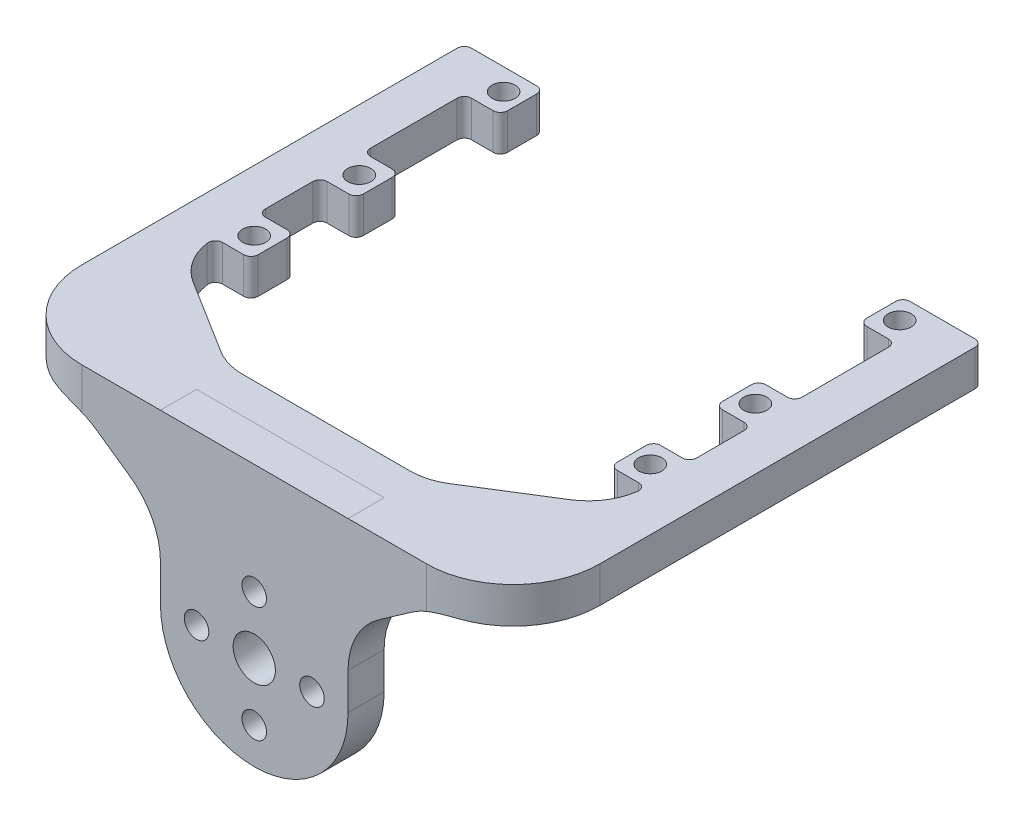
from build123d import *

# Parameters (mm, degrees)
EXTRUDE_1_DEPTH      = 3
SKETCH_7_R           = 2.25
CUT_EXTRUDE_2_DEPTH  = 4.0000001
SKETCH_8_R           = 8
CUT_EXTRUDE_3_DEPTH  = 4.0000001
CUT_EXTRUDE_4_DEPTH  = 3
CUT_EXTRUDE_5_DEPTH  = 3
CUT_EXTRUDE_8_DEPTH  = 3
SKETCH_12_R          = 1.7
CUT_EXTRUDE_9_DEPTH  = 3
SKETCH_13_R          = 1.7
CUT_EXTRUDE_11_DEPTH = 3
CUT_EXTRUDE_12_DEPTH = 4.0000001
FILLET_1_R           = 2
FILLET_2_R           = 2
CUT_EXTRUDE_13_DEPTH = 4.0000001
CUT_EXTRUDE_14_DEPTH = 4.0000001
CUT_EXTRUDE_15_DEPTH = 4.0000001
CUT_EXTRUDE_16_DEPTH = 4.0000001
SKETCH_19_W          = 174.604309186
SKETCH_19_H          = 153.794857067
CUT_EXTRUDE_17_DEPTH = 10
SKETCH_20_R          = 1.7
SKETCH_20_R_2        = 2.929115441
EXTRUDE_2_DEPTH      = 5
SKETCH_21_W          = 71.778327268
SKETCH_21_H          = 4.999657954
EXTRUDE_3_DEPTH      = 5
EXTRUDE_4_DEPTH      = 5
FILLET_3_R           = 10
SKETCH_23_W          = 71.778327268
SKETCH_23_H          = 4.999657954
EXTRUDE_5_DEPTH      = 5
FILLET_4_R           = 1
SKETCH_24_W          = 6
SKETCH_24_H          = 4.999657954
EXTRUDE_7_DEPTH      = 55
EXTRUDE_8_DEPTH      = 4.999658
FILLET_5_R           = 8
FILLET_6_R           = 12
SKETCH_27_W          = 5
SKETCH_27_H          = 6
EXTRUDE_9_DEPTH      = 4.999658
FILLET_7_R           = 1
FILLET_8_R           = 1
FILLET_9_R           = 1
SKETCH_28_R          = 1.6
CUT_EXTRUDE_19_DEPTH = 50
EXTRUDE_10_DEPTH     = 6
SKETCH_33_R          = 1.6
CUT_EXTRUDE_21_DEPTH = 10.999657954
SKETCH_34_W          = 162.843072653
SKETCH_34_H          = 93.113374014
CUT_EXTRUDE_22_DEPTH = 10
SKETCH_35_W          = 6
SKETCH_35_H          = 6
SKETCH_35_R          = 1.6
EXTRUDE_11_DEPTH     = 1
CUT_EXTRUDE_24_DEPTH = 10


with BuildPart() as part:
    # 草图1 → 凸台-拉伸1 (new body)
    with BuildSketch(Plane.XY):
        with BuildLine():
            Line((60, 106.603296002), (35.889163634, 121.664519159))
            Line((35.889163634, 121.664519159), (-35.889163634, 121.664519159))
            Line((-35.889163634, 121.664519159), (-60, 106.603296002))
            Line((-60, 106.603296002), (-60, 94.801892265))
            Line((-60, 94.801892265), (-45, 94.801892265))
            ThreePointArc((-45, 94.801892265), (-43.762563133, 94.289329132), (-43.25, 93.051892265))
            Line((-43.25, 93.051892265), (-37.75, 93.051892265))
            ThreePointArc((-37.75, 93.051892265), (-37.237436867, 94.289329132), (-36, 94.801892265))
            Line((-36, 94.801892265), (-21, 94.801892265))
            ThreePointArc((-21, 94.801892265), (-19.762563133, 94.289329132), (-19.25, 93.051892265))
            Line((-19.25, 93.051892265), (19.25, 93.051892265))
            ThreePointArc((19.25, 93.051892265), (19.762563133, 94.289329132), (21, 94.801892265))
            Line((21, 94.801892265), (36, 94.801892265))
            ThreePointArc((36, 94.801892265), (37.237436867, 94.289329132), (37.75, 93.051892265))
            Line((37.75, 93.051892265), (43.25, 93.051892265))
            ThreePointArc((43.25, 93.051892265), (43.762563133, 94.289329132), (45, 94.801892265))
            Line((45, 94.801892265), (60, 94.801892265))
            Line((60, 94.801892265), (60, 106.603296002))
        make_face()
        with BuildLine():
            Line((66.901694095, 102.292041372), (60, 106.603296002))
            Line((60, 106.603296002), (60, 94.801892265))
            ThreePointArc((60, 94.801892265), (61.237436867, 94.289329132), (61.75, 93.051892265))
            Line((61.75, 93.051892265), (66.901694095, 93.051892265))
            Line((66.901694095, 93.051892265), (66.901694095, 102.292041372))
        make_face()
        with BuildLine():
            Line((-60, 94.801892265), (-60, 106.603296002))
            Line((-60, 106.603296002), (-66.901694095, 102.292041372))
            Line((-66.901694095, 102.292041372), (-66.901694095, 93.051892265))
            Line((-66.901694095, 93.051892265), (-61.75, 93.051892265))
            ThreePointArc((-61.75, 93.051892265), (-61.237436867, 94.289329132), (-60, 94.801892265))
        make_face()
        with BuildLine():
            Line((66.901694095, 63.051892265), (66.901694095, 93.051892265))
            Line((66.901694095, 93.051892265), (61.75, 93.051892265))
            ThreePointArc((61.75, 93.051892265), (61.237436867, 91.814455398), (60, 91.301892265))
            Line((60, 91.301892265), (60, 64.801892265))
            ThreePointArc((60, 64.801892265), (61.237436867, 64.289329132), (61.75, 63.051892265))
            Line((61.75, 63.051892265), (66.901694095, 63.051892265))
        make_face()
        with BuildLine():
            Line((-61.75, 93.051892265), (-66.901694095, 93.051892265))
            Line((-66.901694095, 93.051892265), (-66.901694095, 63.051892265))
            Line((-66.901694095, 63.051892265), (-61.75, 63.051892265))
            ThreePointArc((-61.75, 63.051892265), (-61.237436867, 64.289329132), (-60, 64.801892265))
            Line((-60, 64.801892265), (-60, 91.301892265))
            ThreePointArc((-60, 91.301892265), (-61.237436867, 91.814455398), (-61.75, 93.051892265))
        make_face()
        with BuildLine():
            Line((66.901694095, 52.870133869), (66.901694095, 63.051892265))
            Line((66.901694095, 63.051892265), (61.75, 63.051892265))
            ThreePointArc((61.75, 63.051892265), (61.237436867, 61.814455398), (60, 61.301892265))
            Line((60, 61.301892265), (60, 31.261343001))
            Line((60, 31.261343001), (75, 31.261343001))
            Line((75, 31.261343001), (75, 40.933889795))
            ThreePointArc((75, 40.933889795), (69.117351927, 45.658052319), (66.901694095, 52.870133869))
        make_face()
        with BuildLine():
            Line((60, 64.801892265), (60, 91.301892265))
            Line((60, 91.301892265), (45, 91.301892265))
            ThreePointArc((45, 91.301892265), (43.762563133, 91.814455398), (43.25, 93.051892265))
            Line((43.25, 93.051892265), (37.75, 93.051892265))
            ThreePointArc((37.75, 93.051892265), (37.237436867, 91.814455398), (36, 91.301892265))
            Line((36, 91.301892265), (21, 91.301892265))
            ThreePointArc((21, 91.301892265), (19.762563133, 91.814455398), (19.25, 93.051892265))
            Line((19.25, 93.051892265), (-19.25, 93.051892265))
            ThreePointArc((-19.25, 93.051892265), (-19.762563133, 91.814455398), (-21, 91.301892265))
            Line((-21, 91.301892265), (-36, 91.301892265))
            ThreePointArc((-36, 91.301892265), (-37.237436867, 91.814455398), (-37.75, 93.051892265))
            Line((-37.75, 93.051892265), (-43.25, 93.051892265))
            ThreePointArc((-43.25, 93.051892265), (-43.762563133, 91.814455398), (-45, 91.301892265))
            Line((-45, 91.301892265), (-60, 91.301892265))
            Line((-60, 91.301892265), (-60, 64.801892265))
            Line((-60, 64.801892265), (-45, 64.801892265))
            ThreePointArc((-45, 64.801892265), (-43.762563133, 64.289329132), (-43.25, 63.051892265))
            Line((-43.25, 63.051892265), (-37.75, 63.051892265))
            ThreePointArc((-37.75, 63.051892265), (-37.237436867, 64.289329132), (-36, 64.801892265))
            Line((-36, 64.801892265), (-21, 64.801892265))
            ThreePointArc((-21, 64.801892265), (-19.762563133, 64.289329132), (-19.25, 63.051892265))
            Line((-19.25, 63.051892265), (19.25, 63.051892265))
            ThreePointArc((19.25, 63.051892265), (19.762563133, 64.289329132), (21, 64.801892265))
            Line((21, 64.801892265), (36, 64.801892265))
            ThreePointArc((36, 64.801892265), (37.237436867, 64.289329132), (37.75, 63.051892265))
            Line((37.75, 63.051892265), (43.25, 63.051892265))
            ThreePointArc((43.25, 63.051892265), (43.762563133, 64.289329132), (45, 64.801892265))
            Line((45, 64.801892265), (60, 64.801892265))
        make_face()
        with BuildLine():
            Line((-61.75, 63.051892265), (-66.901694095, 63.051892265))
            Line((-66.901694095, 63.051892265), (-66.901694095, 52.870133869))
            ThreePointArc((-66.901694095, 52.870133869), (-69.117351927, 45.658052319), (-75, 40.933889795))
            Line((-75, 40.933889795), (-75, 31.261343001))
            Line((-75, 31.261343001), (-60, 31.261343001))
            Line((-60, 31.261343001), (-60, 61.301892265))
            ThreePointArc((-60, 61.301892265), (-61.237436867, 61.814455398), (-61.75, 63.051892265))
        make_face()
        with BuildLine():
            Line((60, 31.261343001), (60, 61.301892265))
            Line((60, 61.301892265), (45, 61.301892265))
            ThreePointArc((45, 61.301892265), (43.762563133, 61.814455398), (43.25, 63.051892265))
            Line((43.25, 63.051892265), (37.75, 63.051892265))
            ThreePointArc((37.75, 63.051892265), (37.237436867, 61.814455398), (36, 61.301892265))
            Line((36, 61.301892265), (21, 61.301892265))
            ThreePointArc((21, 61.301892265), (19.762563133, 61.814455398), (19.25, 63.051892265))
            Line((19.25, 63.051892265), (-19.25, 63.051892265))
            ThreePointArc((-19.25, 63.051892265), (-19.762563133, 61.814455398), (-21, 61.301892265))
            Line((-21, 61.301892265), (-36, 61.301892265))
            ThreePointArc((-36, 61.301892265), (-37.237436867, 61.814455398), (-37.75, 63.051892265))
            Line((-37.75, 63.051892265), (-43.25, 63.051892265))
            ThreePointArc((-43.25, 63.051892265), (-43.762563133, 61.814455398), (-45, 61.301892265))
            Line((-45, 61.301892265), (-60, 61.301892265))
            Line((-60, 61.301892265), (-60, 31.261343001))
            Line((-60, 31.261343001), (60, 31.261343001))
        make_face()
        with BuildLine():
            Line((60, -58.312864289), (60, 23.940028391))
            Line((60, 23.940028391), (-60, 23.940028391))
            Line((-60, 23.940028391), (-60, -58.312864289))
            Line((-60, -58.312864289), (-45, -58.312864289))
            ThreePointArc((-45, -58.312864289), (-43.25, -60.062864289), (-45, -61.812864289))
            Line((-45, -61.812864289), (-60, -61.812864289))
            Line((-60, -61.812864289), (-60, -88.312864289))
            Line((-60, -88.312864289), (-45, -88.312864289))
            ThreePointArc((-45, -88.312864289), (-43.25, -90.062864289), (-45, -91.812864289))
            Line((-45, -91.812864289), (-60, -91.812864289))
            Line((-60, -91.812864289), (-60, -111.849967256))
            Line((-60, -111.849967256), (-38.845469114, -105.590576733))
            ThreePointArc((-38.845469114, -105.590576733), (-36.037784492, -104.975210108), (-33.17088573, -104.768665882))
            Line((-33.17088573, -104.768665882), (33.17088573, -104.768665882))
            ThreePointArc((33.17088573, -104.768665882), (36.037784492, -104.975210108), (38.845469114, -105.590576733))
            Line((38.845469114, -105.590576733), (60, -111.849967256))
            Line((60, -111.849967256), (60, -91.812864289))
            Line((60, -91.812864289), (45, -91.812864289))
            ThreePointArc((45, -91.812864289), (43.762563133, -91.300301156), (43.25, -90.062864289))
            ThreePointArc((43.25, -90.062864289), (43.762563133, -88.825427422), (45, -88.312864289))
            Line((45, -88.312864289), (60, -88.312864289))
            Line((60, -88.312864289), (60, -61.812864289))
            Line((60, -61.812864289), (45, -61.812864289))
            ThreePointArc((45, -61.812864289), (43.762563133, -61.300301156), (43.25, -60.062864289))
            ThreePointArc((43.25, -60.062864289), (43.762563133, -58.825427422), (45, -58.312864289))
            Line((45, -58.312864289), (60, -58.312864289))
        make_face()
        with BuildLine():
            ThreePointArc((-21, -88.312864289), (-19.762563133, -88.825427422), (-19.25, -90.062864289))
            ThreePointArc((-19.25, -90.062864289), (-19.762563133, -91.300301156), (-21, -91.812864289))
            Line((-21, -91.812864289), (-36, -91.812864289))
            ThreePointArc((-36, -91.812864289), (-37.75, -90.062864289), (-36, -88.312864289))
            Line((-36, -88.312864289), (-21, -88.312864289))
        make_face(mode=Mode.SUBTRACT)
        with BuildLine():
            ThreePointArc((-21, -58.312864289), (-19.762563133, -58.825427422), (-19.25, -60.062864289))
            ThreePointArc((-19.25, -60.062864289), (-19.762563133, -61.300301156), (-21, -61.812864289))
            Line((-21, -61.812864289), (-36, -61.812864289))
            ThreePointArc((-36, -61.812864289), (-37.75, -60.062864289), (-36, -58.312864289))
            Line((-36, -58.312864289), (-21, -58.312864289))
        make_face(mode=Mode.SUBTRACT)
        with BuildLine():
            ThreePointArc((36, -88.312864289), (37.237436867, -88.825427422), (37.75, -90.062864289))
            ThreePointArc((37.75, -90.062864289), (37.237436867, -91.300301156), (36, -91.812864289))
            Line((36, -91.812864289), (21, -91.812864289))
            ThreePointArc((21, -91.812864289), (19.762563133, -91.300301156), (19.25, -90.062864289))
            ThreePointArc((19.25, -90.062864289), (19.762563133, -88.825427422), (21, -88.312864289))
            Line((21, -88.312864289), (36, -88.312864289))
        make_face(mode=Mode.SUBTRACT)
        with BuildLine():
            ThreePointArc((36, -58.312864289), (37.237436867, -58.825427422), (37.75, -60.062864289))
            ThreePointArc((37.75, -60.062864289), (37.237436867, -61.300301156), (36, -61.812864289))
            Line((36, -61.812864289), (21, -61.812864289))
            ThreePointArc((21, -61.812864289), (19.762563133, -61.300301156), (19.25, -60.062864289))
            ThreePointArc((19.25, -60.062864289), (19.762563133, -58.825427422), (21, -58.312864289))
            Line((21, -58.312864289), (36, -58.312864289))
        make_face(mode=Mode.SUBTRACT)
        with BuildLine():
            Line((75, 23.940028391), (60, 23.940028391))
            Line((60, 23.940028391), (60, -58.312864289))
            ThreePointArc((60, -58.312864289), (61.237436867, -58.825427422), (61.75, -60.062864289))
            Line((61.75, -60.062864289), (67.402721334, -60.062864289))
            add(Edge.make_bspline(
                [(75, 10.562559835), (72.695878257, 1.907314233), (70.339582535, -13.372796253), (67.818206704, -36.939032951), (67.208860388, -51.77269444), (67.402721334, -60.062864289)],
                knots=[0, 0, 0, 0, 0.235246678, 0.40629419, 0.624108181, 0.624108181, 0.624108181, 0.624108181], degree=3))
            Line((75, 10.562559835), (75, 23.940028391))
        make_face()
        with BuildLine():
            Line((-60, -58.312864289), (-60, 23.940028391))
            Line((-60, 23.940028391), (-75, 23.940028391))
            Line((-75, 23.940028391), (-75, 10.562559835))
            add(Edge.make_bspline(
                [(-75, 10.562559835), (-72.695878257, 1.907314233), (-70.339582535, -13.372796253), (-67.818206704, -36.939032951), (-67.208860388, -51.77269444), (-67.402721334, -60.062864289)],
                knots=[0, 0, 0, 0, 0.235246678, 0.40629419, 0.624108181, 0.624108181, 0.624108181, 0.624108181], degree=3))
            add(Edge.make_bspline(
                [(-67.402721334, -60.062864289), (-67.560325872, -66.802583754), (-68.323504015, -76.843670093), (-70.154131955, -86.778530076), (-70.533712858, -90.062864289)],
                knots=[0.624108181, 0.624108181, 0.624108181, 0.624108181, 0.801186001, 0.888408652, 0.888408652, 0.888408652, 0.888408652], degree=3))
            add(Edge.make_bspline(
                [(-70.533712858, -90.062864289), (-71.019342956, -94.264792095), (-71.137422935, -98.476048206), (-70.1742624, -102.732794059)],
                knots=[0.888408652, 0.888408652, 0.888408652, 0.888408652, 1, 1, 1, 1], degree=3))
            Line((-70.1742624, -102.732794059), (-66.460817635, -113.761651372))
            Line((-66.460817635, -113.761651372), (-60, -111.849967256))
            Line((-60, -111.849967256), (-60, -91.812864289))
            ThreePointArc((-60, -91.812864289), (-61.75, -90.062864289), (-60, -88.312864289))
            Line((-60, -88.312864289), (-60, -61.812864289))
            ThreePointArc((-60, -61.812864289), (-61.75, -60.062864289), (-60, -58.312864289))
        make_face()
        with BuildLine():
            Line((67.402721334, -60.062864289), (61.75, -60.062864289))
            ThreePointArc((61.75, -60.062864289), (61.237436867, -61.300301156), (60, -61.812864289))
            Line((60, -61.812864289), (60, -88.312864289))
            ThreePointArc((60, -88.312864289), (61.237436867, -88.825427422), (61.75, -90.062864289))
            Line((61.75, -90.062864289), (70.533712858, -90.062864289))
            add(Edge.make_bspline(
                [(67.402721334, -60.062864289), (67.560325872, -66.802583754), (68.323504015, -76.843670093), (70.154131955, -86.778530076), (70.533712858, -90.062864289)],
                knots=[0.624108181, 0.624108181, 0.624108181, 0.624108181, 0.801186001, 0.888408652, 0.888408652, 0.888408652, 0.888408652], degree=3))
        make_face()
        with BuildLine():
            add(Edge.make_bspline(
                [(70.533712858, -90.062864289), (71.019342956, -94.264792095), (71.137422935, -98.476048206), (70.1742624, -102.732794059)],
                knots=[0.888408652, 0.888408652, 0.888408652, 0.888408652, 1, 1, 1, 1], degree=3))
            Line((70.533712858, -90.062864289), (61.75, -90.062864289))
            ThreePointArc((61.75, -90.062864289), (61.237436867, -91.300301156), (60, -91.812864289))
            Line((60, -91.812864289), (60, -111.849967256))
            Line((60, -111.849967256), (66.460817635, -113.761651372))
            Line((66.460817635, -113.761651372), (70.1742624, -102.732794059))
        make_face()
    extrude(amount=EXTRUDE_1_DEPTH)

    # 草图7 → 切除-拉伸2 (cut, through all)
    with BuildSketch(Plane(origin=(0, 0, 0), x_dir=(-1, 0, 0), z_dir=(0, 0, -1))):
        with Locations((-21, 41.261343001)):
            Circle(SKETCH_7_R)
        with Locations((21, 41.261343001)):
            Circle(SKETCH_7_R)
        with Locations((-21, 13.940028391)):
            Circle(SKETCH_7_R)
        with Locations((21, 13.940028391)):
            Circle(SKETCH_7_R)
    extrude(amount=-CUT_EXTRUDE_2_DEPTH, mode=Mode.SUBTRACT)

    # 草图8 → 切除-拉伸3 (cut, through all)
    with BuildSketch(Plane.XY.offset(3)):
        with BuildLine():
            Line((-12.621438714, -0.378557945), (-33.409010345, 20.409013685))
            ThreePointArc((-33.409010345, 20.409013685), (-36.590999434, 20.409013643), (-36.590999309, 17.227024553))
            Line((-36.590999309, 17.227024553), (-15.803426586, -3.560545984))
            ThreePointArc((-15.803426586, -3.560545984), (-12.621438673, -3.560545859), (-12.621438714, -0.378557945))
        make_face()
        with BuildLine():
            Line((33.410462056, 20.410458798), (12.572988319, -0.427010824))
            ThreePointArc((12.572988319, -0.427010824), (12.644570441, -3.584764993), (15.803045702, -3.56090242))
            Line((15.803045702, -3.56090242), (34.999999982, 15.636052774))
            Line((34.999999982, 15.636052774), (36.588086952, 17.224139819))
            ThreePointArc((36.588086952, 17.224139819), (36.592433993, 20.406111757), (33.410462056, 20.410458798))
        make_face()
        with BuildLine():
            Line((-15.803784812, -28.80377835), (-36.591002186, -49.590991619))
            ThreePointArc((-36.591002186, -49.590991619), (-36.591002403, -52.772972232), (-33.40902179, -52.772972254))
            Line((-33.40902179, -52.772972254), (-12.573723916, -31.937673388))
            ThreePointArc((-12.573723916, -31.937673388), (-12.64530628, -28.779915954), (-15.803784812, -28.80377835))
        make_face()
        with BuildLine():
            Line((36.590992666, -49.590989326), (15.803414627, -28.803411286))
            ThreePointArc((15.803414627, -28.803411286), (12.654338964, -28.769774302), (12.55344336, -31.917412949))
            Line((12.55344336, -31.917412949), (33.409007381, -52.772974779))
            ThreePointArc((33.409007381, -52.772974779), (36.590992708, -52.772974653), (36.590992666, -49.590989326))
        make_face()
        with Locations((-0.000368782, -16.182341354)):
            Circle(SKETCH_8_R)
    extrude(amount=-CUT_EXTRUDE_3_DEPTH, mode=Mode.SUBTRACT)

    # 草图9 → 切除-拉伸4 (cut)
    with BuildSketch(Plane.XY.offset(3)):
        with BuildLine():
            Line((55, -100.49704609), (20, -100.49704609))
            ThreePointArc((20, -100.49704609), (18.25, -98.74704609), (20, -96.99704609))
            Line((20, -96.99704609), (55, -96.99704609))
            ThreePointArc((55, -96.99704609), (56.75, -98.74704609), (55, -100.49704609))
        make_face()
        with BuildLine():
            Line((-55, -96.99704609), (-20, -96.99704609))
            ThreePointArc((-20, -96.99704609), (-18.25, -98.74704609), (-20, -100.49704609))
            Line((-20, -100.49704609), (-55, -100.49704609))
            ThreePointArc((-55, -100.49704609), (-56.75, -98.74704609), (-55, -96.99704609))
        make_face()
    extrude(amount=-CUT_EXTRUDE_4_DEPTH, mode=Mode.SUBTRACT)

    # 草图10 → 切除-拉伸5 (cut)
    with BuildSketch(Plane.XY.offset(3)):
        with BuildLine():
            Line((12.5, -80.062864289), (-12.5, -80.062864289))
            ThreePointArc((-12.5, -80.062864289), (-17.5, -75.062864289), (-12.5, -70.062864289))
            Line((-12.5, -70.062864289), (12.5, -70.062864289))
            ThreePointArc((12.5, -70.062864289), (17.5, -75.062864289), (12.5, -80.062864289))
        make_face()
    extrude(amount=-CUT_EXTRUDE_5_DEPTH, mode=Mode.SUBTRACT)

    # 草图11 → 切除-拉伸8 (cut)
    with BuildSketch(Plane.XY.offset(3)):
        with BuildLine():
            Line((15, 73.051892265), (-15, 73.051892265))
            ThreePointArc((-15, 73.051892265), (-20, 78.051892265), (-15, 83.051892265))
            Line((-15, 83.051892265), (15, 83.051892265))
            ThreePointArc((15, 83.051892265), (20, 78.051892265), (15, 73.051892265))
        make_face()
    extrude(amount=-CUT_EXTRUDE_8_DEPTH, mode=Mode.SUBTRACT)

    # 草图12 → 切除-拉伸9 (cut)
    with BuildSketch(Plane.XY.offset(3)):
        with Locations((0, 114.371786435)):
            Circle(SKETCH_12_R)
        with Locations((0, 98.371786435)):
            Circle(SKETCH_12_R)
        with Locations((8, 106.371786435)):
            Circle(SKETCH_12_R)
        with Locations((-8, 106.371786435)):
            Circle(SKETCH_12_R)
    extrude(amount=-CUT_EXTRUDE_9_DEPTH, mode=Mode.SUBTRACT)

    # 草图13 → 切除-拉伸11 (cut)
    with BuildSketch(Plane.XY.offset(3)):
        with Locations((0, -84.415765086)):
            Circle(SKETCH_13_R)
        with Locations((8, -92.415765086)):
            Circle(SKETCH_13_R)
        with Locations((0, -100.415765086)):
            Circle(SKETCH_13_R)
        with Locations((-8, -92.415765086)):
            Circle(SKETCH_13_R)
    extrude(amount=-CUT_EXTRUDE_11_DEPTH, mode=Mode.SUBTRACT)

    # 草图14 → 切除-拉伸12 (cut, through all)
    with BuildSketch(Plane.XY.offset(3)):
        with BuildLine():
            Line((-55.475501567, 8.919687236), (-55.475501567, -46.080312764))
            ThreePointArc((-55.475501567, -46.080312764), (-57.225501567, -47.830312764), (-58.975501567, -46.080312764))
            Line((-58.975501567, -46.080312764), (-58.975501567, 8.919687236))
            ThreePointArc((-58.975501567, 8.919687236), (-57.225501567, 10.669687236), (-55.475501567, 8.919687236))
        make_face()
        with BuildLine():
            Line((58.975501567, 8.919687236), (58.975501567, -46.080312764))
            ThreePointArc((58.975501567, -46.080312764), (57.225501567, -47.830312764), (55.475501567, -46.080312764))
            Line((55.475501567, -46.080312764), (55.475501567, 8.919687236))
            ThreePointArc((55.475501567, 8.919687236), (57.225501567, 10.669687236), (58.975501567, 8.919687236))
        make_face()
    extrude(amount=-CUT_EXTRUDE_12_DEPTH, mode=Mode.SUBTRACT)

    # 圆角1
    fillet_1_edges = [part.edges().sort_by_distance(p)[0] for p in [
        (75, 31.261343001, 1.5),
        (-75, 31.261343001, 1.5),
    ]]
    fillet(fillet_1_edges, radius=FILLET_1_R)

    # 圆角2
    fillet_2_edges = [part.edges().sort_by_distance(p)[0] for p in [
        (-75, 23.940028391, 1.5),
        (75, 23.940028391, 1.5),
    ]]
    fillet(fillet_2_edges, radius=FILLET_2_R)

    # 草图15 → 切除-拉伸13 (cut, through all)
    with BuildSketch(Plane(origin=(0, 0, 0), x_dir=(-1, 0, 0), z_dir=(0, 0, -1))):
        with BuildLine():
            Line((-61.184216401, 102.403501276), (-34.774762862, 118.900592756))
            ThreePointArc((-34.774762862, 118.900592756), (-32.70788159, 118.423097411), (-33.185376934, 116.356216138))
            Line((-33.185376934, 116.356216138), (-59.594830473, 99.859124658))
            ThreePointArc((-59.594830473, 99.859124658), (-61.661711746, 100.336620003), (-61.184216401, 102.403501276))
        make_face()
        with BuildLine():
            Line((59.594830473, 99.859124658), (33.185376934, 116.356216138))
            ThreePointArc((33.185376934, 116.356216138), (32.70788159, 118.423097411), (34.774762862, 118.900592756))
            Line((34.774762862, 118.900592756), (61.184216401, 102.403501276))
            ThreePointArc((61.184216401, 102.403501276), (61.661711746, 100.336620003), (59.594830473, 99.859124658))
        make_face()
    extrude(amount=-CUT_EXTRUDE_13_DEPTH, mode=Mode.SUBTRACT)

    # 草图16 → 切除-拉伸14 (cut, through all)
    with BuildSketch(Plane(origin=(0, 0, 0), x_dir=(-1, 0, 0), z_dir=(0, 0, -1))):
        with BuildLine():
            Line((-61.516979467, 42.761343001), (-32.056291893, 42.761343001))
            ThreePointArc((-32.056291893, 42.761343001), (-30.556291893, 41.261343001), (-32.056291893, 39.761343001))
            Line((-32.056291893, 39.761343001), (-61.516979467, 39.761343001))
            ThreePointArc((-61.516979467, 39.761343001), (-63.016979467, 41.261343001), (-61.516979467, 42.761343001))
        make_face()
        with BuildLine():
            Line((61.516979467, 39.761343001), (32.056291893, 39.761343001))
            ThreePointArc((32.056291893, 39.761343001), (30.556291893, 41.261343001), (32.056291893, 42.761343001))
            Line((32.056291893, 42.761343001), (61.516979467, 42.761343001))
            ThreePointArc((61.516979467, 42.761343001), (63.016979467, 41.261343001), (61.516979467, 39.761343001))
        make_face()
    extrude(amount=-CUT_EXTRUDE_14_DEPTH, mode=Mode.SUBTRACT)

    # 草图17 → 切除-拉伸15 (cut, through all)
    with BuildSketch(Plane(origin=(0, 0, 0), x_dir=(-1, 0, 0), z_dir=(0, 0, -1))):
        Polygon((-28.645414283, -8.118433382), (-34.644957411, -20.11751964), (-34.644957411, -29.946558382), (-37.580904049, -29.946558382), (-37.580904049, -20.11751964), (-43.580447177, -8.118433382), (-40.64450054, -8.118433382), (-36.176755657, -17.43687271), (-36.049105803, -17.43687271), (-31.58136092, -8.118433382), align=None)
    extrude(amount=-CUT_EXTRUDE_15_DEPTH, mode=Mode.SUBTRACT)

    # 草图18 → 切除-拉伸16 (cut, through all)
    with BuildSketch(Plane(origin=(0, 0, 0), x_dir=(-1, 0, 0), z_dir=(0, 0, -1))):
        Polygon((46.06697123, -29.087529791), (43.131024593, -29.087529791), (43.131024593, -18.875541487), (35.854982926, -18.875541487), (35.854982926, -29.087529791), (32.919036289, -29.087529791), (32.919036289, -7.259404791), (35.854982926, -7.259404791), (35.854982926, -16.450194265), (43.131024593, -16.450194265), (43.131024593, -7.259404791), (46.06697123, -7.259404791), align=None)
    extrude(amount=-CUT_EXTRUDE_16_DEPTH, mode=Mode.SUBTRACT)

    # 草图19 → 切除-拉伸17 (cut)
    with BuildSketch(Plane(origin=(0, 0, 0), x_dir=(-1, 0, 0), z_dir=(0, 0, -1))):
        with Locations((0, -49.372787161)):
            Rectangle(SKETCH_19_W, SKETCH_19_H)
    extrude(amount=-CUT_EXTRUDE_17_DEPTH, mode=Mode.SUBTRACT)

    # 草图34 → 切除-拉伸22 (cut)
    with BuildSketch(Plane(origin=(0, 0, 0), x_dir=(-1, 0, 0), z_dir=(0, 0, -1))):
        with Locations((1.208964771, 75.898201893)):
            Rectangle(SKETCH_34_W, SKETCH_34_H)
    extrude(amount=-CUT_EXTRUDE_22_DEPTH, mode=Mode.SUBTRACT)


with BuildPart() as body_2:
    # 草图20 → 凸台-拉伸2 (new body)
    with BuildSketch(Plane.XY.offset(13)):
        with BuildLine():
            Line((-13, 106.371786435), (-13, 129.664519159))
            Line((-13, 129.664519159), (13, 129.664519159))
            Line((13, 129.664519159), (13, 106.371786435))
            ThreePointArc((13, 106.371786435), (0, 93.371786435), (-13, 106.371786435))
        make_face()
        with Locations((0, 98.371786435)):
            Circle(SKETCH_20_R, mode=Mode.SUBTRACT)
        with Locations((-8, 106.371786435)):
            Circle(SKETCH_20_R, mode=Mode.SUBTRACT)
        with Locations((8, 106.371786435)):
            Circle(SKETCH_20_R, mode=Mode.SUBTRACT)
        with Locations((0, 114.371786435)):
            Circle(SKETCH_20_R, mode=Mode.SUBTRACT)
        with Locations((0, 106.371786435)):
            Circle(SKETCH_20_R_2, mode=Mode.SUBTRACT)
    extrude(amount=EXTRUDE_2_DEPTH)

    # 草图21 → 凸台-拉伸3 (add)
    with BuildSketch(Plane.XY.offset(18)):
        with Locations((0, 127.164522428)):
            Rectangle(SKETCH_21_W, SKETCH_21_H)
    extrude(amount=-EXTRUDE_3_DEPTH)

    # 草图22 → 凸台-拉伸4 (add)
    with BuildSketch(Plane.XY.offset(18)):
        Polygon((-24.444581817, 124.664693451), (-13, 116.664693451), (-13, 124.664693451), align=None)
        Polygon((24.444581817, 124.664693451), (13, 116.664693451), (13, 124.664693451), align=None)
    extrude(amount=-EXTRUDE_4_DEPTH)

    # 圆角3
    fillet_3_edges = [body_2.edges().sort_by_distance(p)[0] for p in [
        (-24.444581817, 124.664693451, 15.5),
        (-13, 116.664693451, 15.5),
        (24.444581817, 124.664693451, 15.5),
        (13, 116.664693451, 15.5),
    ]]
    fillet(fillet_3_edges, radius=FILLET_3_R)

    # 草图23 → 凸台-拉伸5 (add)
    with BuildSketch(Plane(origin=(0, 0, 13), x_dir=(-1, 0, 0), z_dir=(0, 0, -1))):
        with Locations((0, 127.164522428)):
            Rectangle(SKETCH_23_W, SKETCH_23_H)
    extrude(amount=EXTRUDE_5_DEPTH)

    # 圆角4
    fillet_4_edges = [body_2.edges().sort_by_distance(p)[0] for p in [
        (0, 124.664693451, 13),
    ]]
    fillet(fillet_4_edges, radius=FILLET_4_R)

    # 草图24 → 凸台-拉伸7 (add)
    with BuildSketch(Plane(origin=(0, 0, 8), x_dir=(-1, 0, 0), z_dir=(0, 0, -1))):
        with Locations((-32.889163634, 127.164522428)):
            Rectangle(SKETCH_24_W, SKETCH_24_H)
        with Locations((32.889163634, 127.164522428)):
            Rectangle(SKETCH_24_W, SKETCH_24_H)
    extrude(amount=EXTRUDE_7_DEPTH)

    # 草图25 → 凸台-拉伸8 (add)
    with BuildSketch(Plane(origin=(0, 129.664351405, 0), x_dir=(1, 0, 0), z_dir=(0, 1, 0))):
        Polygon((-29.889163634, 2), (-13.889163634, -8), (-29.889163634, -8), align=None)
        Polygon((29.889163634, -8), (13.889163634, -8), (29.889163634, 2), align=None)
    extrude(amount=-EXTRUDE_8_DEPTH)

    # 圆角5
    fillet_5_edges = [body_2.edges().sort_by_distance(p)[0] for p in [
        (-13.889163634, 127.164522405, 8),
        (-29.889163634, 127.164522405, -2),
        (13.889163634, 127.164522405, 8),
        (29.889163634, 127.164522405, -2),
    ]]
    fillet(fillet_5_edges, radius=FILLET_5_R)

    # 圆角6
    fillet_6_edges = [body_2.edges().sort_by_distance(p)[0] for p in [
        (35.889163634, 127.164522428, 18),
        (-35.889163634, 127.164522428, 18),
    ]]
    fillet(fillet_6_edges, radius=FILLET_6_R)

    # 草图27 → 凸台-拉伸9 (add)
    with BuildSketch(Plane(origin=(0, 129.664351405, 0), x_dir=(1, 0, 0), z_dir=(0, 1, 0))):
        with Locations((-27.389163634, 9.433981132)):
            Rectangle(SKETCH_27_W, SKETCH_27_H)
        with Locations((-27.389163634, 24)):
            Rectangle(SKETCH_27_W, SKETCH_27_H)
        with Locations((27.389163634, 24)):
            Rectangle(SKETCH_27_W, SKETCH_27_H)
        with Locations((27.389163634, 9.433981132)):
            Rectangle(SKETCH_27_W, SKETCH_27_H)
        with Locations((-27.389163634, 44)):
            Rectangle(SKETCH_27_W, SKETCH_27_H)
        with Locations((27.389163634, 44)):
            Rectangle(SKETCH_27_W, SKETCH_27_H)
    extrude(amount=-EXTRUDE_9_DEPTH)

    # 圆角7
    fillet_7_edges = [body_2.edges().sort_by_distance(p)[0] for p in [
        (29.889163634, 127.164522428, -6.433981132),
        (-29.889163634, 127.164522428, -6.433981132),
        (-29.889163634, 127.164522405, -12.433981132),
        (-29.889163634, 127.164522405, -41),
        (29.889163634, 127.164522405, -41),
        (-29.889163634, 127.164522405, -27),
        (-29.889163634, 127.164522405, -21),
        (29.889163634, 127.164522405, -21),
        (29.889163634, 127.164522405, -27),
        (29.889163634, 127.164522405, -12.433981132),
    ]]
    fillet(fillet_7_edges, radius=FILLET_7_R)

    # 圆角8
    fillet_8_edges = [body_2.edges().sort_by_distance(p)[0] for p in [
        (-24.889163634, 127.164522405, -6.433981132),
        (-24.889163634, 127.164522405, -12.433981132),
        (-24.889163634, 127.164522405, -41),
        (24.889163634, 127.164522405, -41),
        (-24.889163634, 127.164522405, -21),
        (-24.889163634, 127.164522405, -27),
        (24.889163634, 127.164522405, -21),
        (24.889163634, 127.164522405, -27),
        (24.889163634, 127.164522405, -12.433981132),
        (24.889163634, 127.164522405, -6.433981132),
    ]]
    fillet(fillet_8_edges, radius=FILLET_8_R)

    # 圆角9
    fillet_9_edges = [body_2.edges().sort_by_distance(p)[0] for p in [
        (35.889163634, 127.164522428, -47),
        (-35.889163634, 127.164522428, -47),
        (-24.889163634, 127.164522405, -47),
        (24.889163634, 127.164522405, -47),
    ]]
    fillet(fillet_9_edges, radius=FILLET_9_R)

    # 草图28 → 切除-拉伸19 (cut)
    with BuildSketch(Plane(origin=(0, 129.664351405, 0), x_dir=(1, 0, 0), z_dir=(0, 1, 0))):
        with Locations((-27.445843009, 44)):
            Circle(SKETCH_28_R)
        with Locations((-27.445843009, 24)):
            Circle(SKETCH_28_R)
        with Locations((-27.445843009, 9.433981132)):
            Circle(SKETCH_28_R)
        with Locations((27.445843009, 9.433981132)):
            Circle(SKETCH_28_R)
        with Locations((27.445843009, 24)):
            Circle(SKETCH_28_R)
        with Locations((27.445843009, 44)):
            Circle(SKETCH_28_R)
    extrude(amount=-CUT_EXTRUDE_19_DEPTH, mode=Mode.SUBTRACT)

    # 草图32 → 凸台-拉伸10 (add)
    with BuildSketch(Plane.XY.offset(-6.433981132)):
        Polygon((-35.889163634, 129.664351405), (-56.41665643, 116.841521654), (-58.663321092, 120.438106306), (-35.889163634, 134.664351405), (35.889163634, 134.664351405), (58.663321092, 120.438106306), (56.41665643, 116.841521654), (35.889163634, 129.664351405), align=None)
    extrude(amount=-EXTRUDE_10_DEPTH)

    # 草图33 → 切除-拉伸21 (cut, through all)
    with BuildSketch(Plane.XZ.offset(-124.664693451)):
        with Locations((-27.445843009, -9.433981132)):
            Circle(SKETCH_33_R)
        with Locations((27.445843009, -9.433981132)):
            Circle(SKETCH_33_R)
    extrude(amount=-CUT_EXTRUDE_21_DEPTH, mode=Mode.SUBTRACT)

    # 草图35 → 凸台-拉伸11 (add)
    with BuildSketch(Plane(origin=(0, 134.664351405, 0), x_dir=(1, 0, 0), z_dir=(0, 1, 0))):
        with Locations((-27.445843009, 9.433981132)):
            Rectangle(SKETCH_35_W, SKETCH_35_H)
        with Locations((-27.445843009, 9.433981132)):
            Circle(SKETCH_35_R, mode=Mode.SUBTRACT)
        with Locations((27.445843009, 9.433981132)):
            Rectangle(SKETCH_35_W, SKETCH_35_H)
        with Locations((27.445843009, 9.433981132)):
            Circle(SKETCH_35_R, mode=Mode.SUBTRACT)
    extrude(amount=EXTRUDE_11_DEPTH)

    # 草图36 → 切除-拉伸24 (cut)
    with BuildSketch(Plane(origin=(0, 0, -12.433981132), x_dir=(-1, 0, 0), z_dir=(0, 0, -1))):
        Polygon((25.889163634, 129.664351405), (28.889163634, 129.664351405), (35.889163634, 129.664351405), (56.41665643, 116.841521654), (58.663321092, 120.438106306), (35.889163634, 134.664351405), (30.445843009, 134.664351405), (30.445843009, 135.664351405), (24.445843009, 135.664351405), (24.445843009, 134.664351405), (-24.445843009, 134.664351405), (-24.445843009, 135.664351405), (-30.445843009, 135.664351405), (-30.445843009, 134.664351405), (-35.889163634, 134.664351405), (-58.663321092, 120.438106306), (-56.41665643, 116.841521654), (-35.889163634, 129.664351405), (-28.889163634, 129.664351405), (-25.889163634, 129.664351405), align=None)
    extrude(amount=-CUT_EXTRUDE_24_DEPTH, mode=Mode.SUBTRACT)


solid = body_2.part
